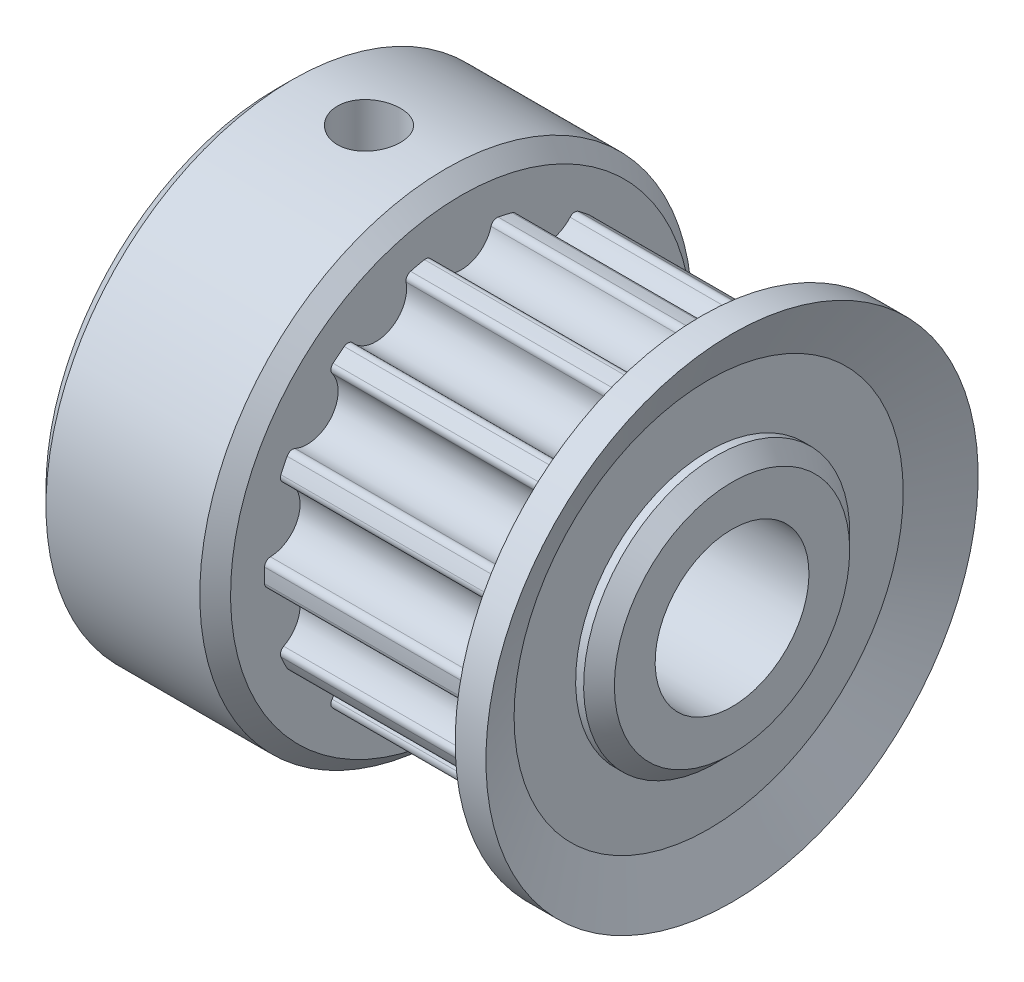
from build123d import *

# Parameters (mm, degrees)
SKETCH6_R                = 2.5
CUT_EXTRUDE3_DEPTH       = 19.629009636
SKETCH7_R                = 1
CUT_EXTRUDE4_DEPTH       = 7
FILLET2_R                = 0.2
CIRPATTERN3_COUNT        = 14
FILLET2_OF_CIRPATTERN3_R = 0.2
M2_5_TAPPED_HOLE1_REACH  = 25.217
M2_5_TAPPED_HOLE1_BORE_R = 1.025


with BuildPart() as part:
    # Sketch5 → Revolve2 (revolve)
    with BuildSketch(Plane.XY):
        Polygon((0, 0), (0, 3.5), (0.3, 3.8), (0, 3.8), (0, 7.5), (0.5, 8), (5.5, 8), (6, 7.5), (6, 6.4), (13, 6.4), (13.8, 8), (14.8, 8), (14.04, 6.324291195), (14.04, 4.324291195), (14.3, 4.324291195), (14.8, 3.824291195), (14.8, 0), align=None)
    revolve(axis=Axis((14.8, 0, 0), (-1, 0, 0)))

    # Sketch6 → Cut-Extrude3 (cut, through all)
    with BuildSketch(Plane(origin=(14.8, 0, 0), x_dir=(0, 0, -1), z_dir=(1, 0, 0))):
        with Locations(Location((0, 0, 0), (0, 0, 90))):
            Circle(SKETCH6_R)
    extrude(amount=-CUT_EXTRUDE3_DEPTH, mode=Mode.SUBTRACT)

    # Sketch7 → Cut-Extrude4 (cut)
    with BuildSketch(Plane(origin=(6, 0, 0), x_dir=(0, 0, -1), z_dir=(1, 0, 0))):
        with Locations((0, 6.4)):
            Circle(SKETCH7_R)
    cut_extrude4 = extrude(amount=CUT_EXTRUDE4_DEPTH, mode=Mode.SUBTRACT)

    # Fillet2
    fillet2_edges = [part.edges().sort_by_distance(p)[0] for p in [
        (9.5, 6.321875, 0.996943571),
        (9.5, 6.321875, -0.996943571),
    ]]
    fillet(fillet2_edges, radius=FILLET2_R)

    # CirPattern3: Cut-Extrude4 ×14 about axis
    cirpattern3_axis = Axis((0, 0, 0), (1, 0, 0))
    for i in range(1, CIRPATTERN3_COUNT):
        add(cut_extrude4.rotate(cirpattern3_axis, i * 360 / CIRPATTERN3_COUNT), mode=Mode.SUBTRACT)

    # Fillet2 of CirPattern3
    fillet2_of_cirpattern3_edges = [part.edges().sort_by_distance(p)[0] for p in [
        (9.5, 5.263254957, 3.641173884),
        (9.5, 6.128370166, 1.844743642),
        (9.5, 3.162182721, 5.564225053),
        (9.5, 4.721066461, 4.321056753),
        (9.5, 0.434801415, 6.385213209),
        (9.5, 2.378697644, 5.94153158),
        (9.5, -2.378697644, 5.94153158),
        (9.5, -0.434801415, 6.385213209),
        (9.5, -4.721066461, 4.321056753),
        (9.5, -3.162182721, 5.564225053),
        (9.5, -6.128370166, 1.844743642),
        (9.5, -5.263254957, 3.641173884),
        (9.5, -6.321875, -0.996943571),
        (9.5, -6.321875, 0.996943571),
        (9.5, -5.263254957, -3.641173884),
        (9.5, -6.128370166, -1.844743642),
        (9.5, -3.162182721, -5.564225053),
        (9.5, -4.721066461, -4.321056753),
        (9.5, -0.434801415, -6.385213209),
        (9.5, -2.378697644, -5.94153158),
        (9.5, 2.378697644, -5.94153158),
        (9.5, 0.434801415, -6.385213209),
        (9.5, 4.721066461, -4.321056753),
        (9.5, 3.162182721, -5.564225053),
        (9.5, 6.128370166, -1.844743642),
        (9.5, 5.263254957, -3.641173884),
    ]]
    fillet(fillet2_of_cirpattern3_edges, radius=FILLET2_OF_CIRPATTERN3_R)

    # M2.5 Tapped Hole1 bore → M2.5 Tapped Hole1 (cut, up to next)
    with BuildSketch(Plane(origin=(0, 8, 0), x_dir=(1, 0, 0), z_dir=(0, 1, 0)), mode=Mode.PRIVATE) as m2_5_tapped_hole1_sk1:
        with Locations((3, 0)):
            Circle(M2_5_TAPPED_HOLE1_BORE_R)
    m2_5_tapped_hole1_tool1 = extrude(m2_5_tapped_hole1_sk1.sketch, amount=-M2_5_TAPPED_HOLE1_REACH, mode=Mode.PRIVATE) & part.part
    add(m2_5_tapped_hole1_tool1.solids().sort_by_distance((3, 8, 0))[0], mode=Mode.SUBTRACT)


solid = part.part
